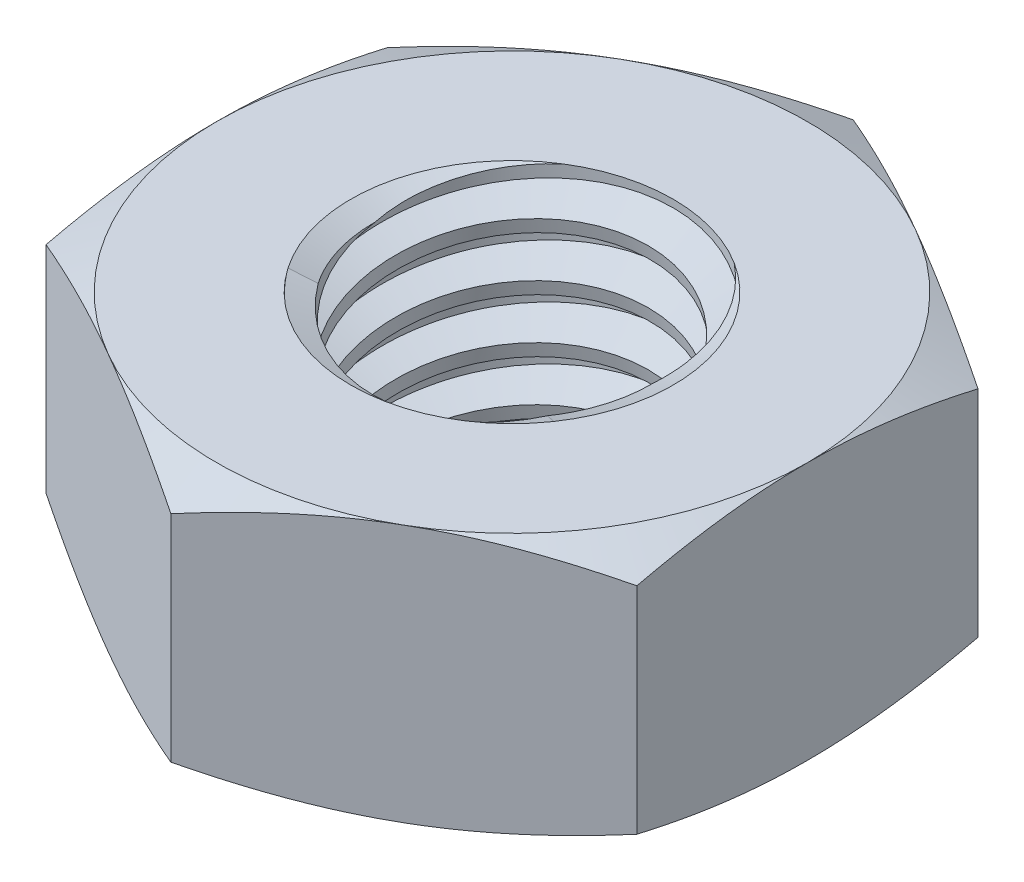
from build123d import *

# Parameters (mm, degrees)
EXTRUDE1_DEPTH      = 1.2
SKETCH2_W           = 1.5
SKETCH2_H           = 2.4
LPATTERN1_COUNT     = 5
LPATTERN1_PITCH     = 0.5
LPATTERN1_COL_COUNT = 2
LPATTERN1_COL_PITCH = 0.5


with BuildPart() as part:
    # Sketch1 → Extrude1 (new body, symmetric)
    with BuildSketch(Plane(origin=(0, 0, 0), x_dir=(1, 0, 0), z_dir=(0, 1, 0))):
        Polygon((0, 3.175426481), (-2.75, 1.58771324), (-2.75, -1.58771324), (0, -3.175426481), (2.75, -1.58771324), (2.75, 1.58771324), align=None)
    extrude(amount=EXTRUDE1_DEPTH, both=True)

    # Sketch4 → Cut-Revolve2 (revolve, cut)
    with BuildSketch(Plane(origin=(0, 0, 0), x_dir=(0, 0, -1), z_dir=(1, 0, 0))):
        Polygon((0, 1.2), (1.5, 1.2), (1.269011592, 1.092288336), (1.269011592, -1.092288336), (1.5, -1.2), (0, -1.2), align=None)
    revolve(axis=Axis((0, 1.2, 0), (0, 1, 0)), mode=Mode.SUBTRACT)


with BuildPart() as body_2:
    # Sketch2 → Revolve1 (revolve)
    with BuildSketch(Plane(origin=(0, 0, 0), x_dir=(0, 0, -1), z_dir=(1, 0, 0))):
        with Locations((0.75, 0)):
            Rectangle(SKETCH2_W, SKETCH2_H)
    revolve(axis=Axis((0, -2.7, 0), (0, 1, 0)))

    # Sketch3 → Cut-Revolve1 (revolve, cut)
    with BuildSketch(Plane(origin=(0, 0, 0), x_dir=(0, 0, -1), z_dir=(1, 0, 0))):
        Polygon((1.510274937, 1.13835038), (1.582199494, 0.706803038), (1.289561466, 0.816435308), (1.269011592, 0.939734548), align=None)
    cut_revolve1 = revolve(axis=Axis((0, 1.2, 0.089188249), (0, -0.986393924, -0.164398987)), mode=Mode.SUBTRACT)

    # LPattern1: Cut-Revolve1 ×5
    with Locations(*[(0, -i * LPATTERN1_PITCH, 0) for i in range(1, LPATTERN1_COUNT)]):
        add(cut_revolve1, mode=Mode.SUBTRACT)

    # LPattern1 col: Cut-Revolve1 ×2
    with Locations(*[(0, i * LPATTERN1_COL_PITCH, 0) for i in range(1, LPATTERN1_COL_COUNT)]):
        add(cut_revolve1, mode=Mode.SUBTRACT)


with BuildPart() as part_1:
    add(part.part)

    # Combine1: cut body 2
    add(body_2.part, mode=Mode.SUBTRACT)

    # Sketch5 → Cut-Revolve3 (revolve, cut)
    with BuildSketch(Plane(origin=(0, 0, 0), x_dir=(0, 0, -1), z_dir=(1, 0, 0))):
        Polygon((0, -1.2), (2.75, -1.2), (3.175426481, -1.001620374), (3.175426481, 1.001620374), (2.75, 1.2), (0, 1.2), (0, 2.47), (4.445426481, 2.47), (4.445426481, -2.47), (0, -2.47), align=None)
    revolve(axis=Axis((0, -1.2, 0), (0, 1, 0)), mode=Mode.SUBTRACT)


solid = part_1.part
